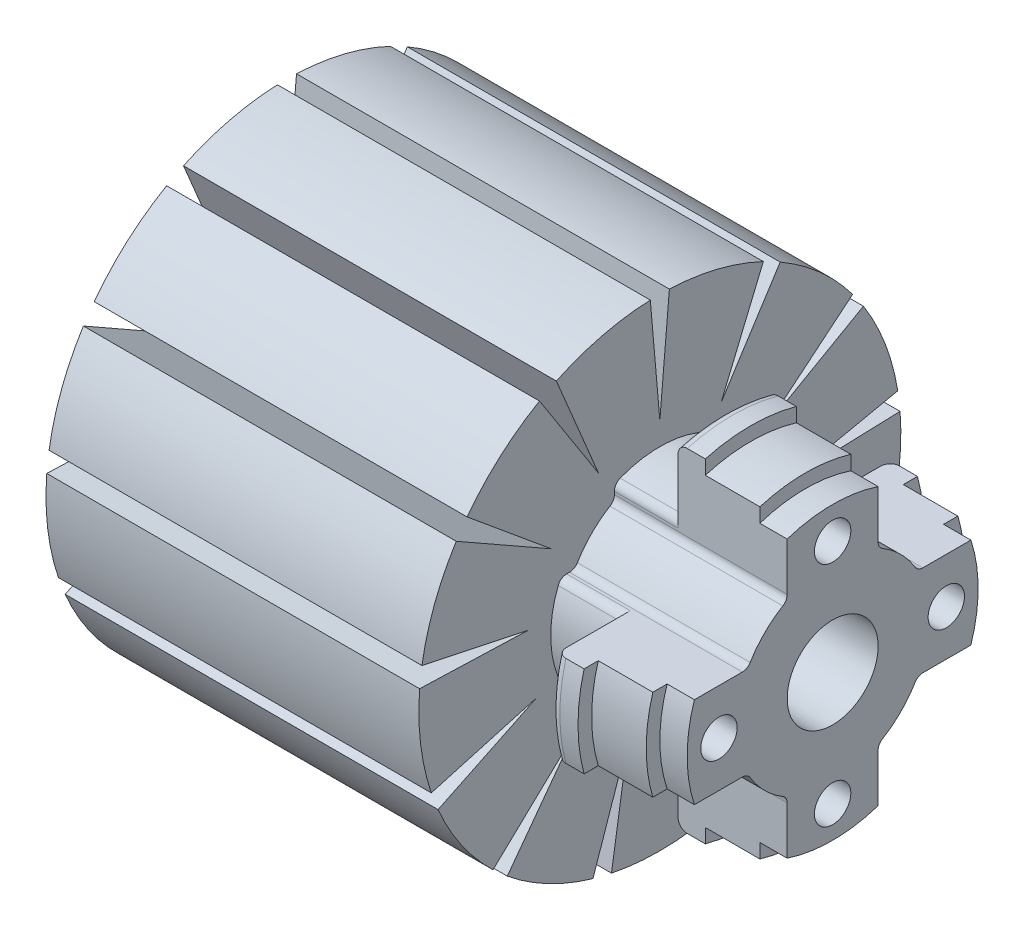
from build123d import *

# Parameters (mm, degrees)
SKETCH1_R      = 26.5
SKETCH1_R_2    = 5
EXTRUDE1_DEPTH = 60
SKETCH3_R      = 2
EXTRUDE2_DEPTH = 10
EXTRUDE3_START = -41
EXTRUDE3_DEPTH = 41
EXTRUDE4_DEPTH = 19
FILLET1_R      = 1


with BuildPart() as part:
    # Sketch1 → Extrude1 (new body)
    with BuildSketch(Plane(origin=(0, 0, 0), x_dir=(0, 0, -1), z_dir=(1, 0, 0))):
        Circle(SKETCH1_R)
        Circle(SKETCH1_R_2, mode=Mode.SUBTRACT)
    extrude(amount=EXTRUDE1_DEPTH)

    # Sketch2 → Cut-Revolve1 (revolve, cut)
    with BuildSketch(Plane.XY):
        Polygon((60, 16), (60, 26.5), (41, 26.5), (41, 12), (48, 12), (48, 19), (51, 19), (51, 17.5), (57, 17.5), (57, 16), align=None)
    revolve(axis=Axis((0, 0, 0), (1, 0, 0)), mode=Mode.SUBTRACT)

    # Sketch3 → Extrude2 (cut)
    with BuildSketch(Plane(origin=(60, 0, 0), x_dir=(0, 0, -1), z_dir=(1, 0, 0))):
        with Locations((0, 12.5)):
            Circle(SKETCH3_R)
        with Locations((12.5, 0)):
            Circle(SKETCH3_R)
        with Locations((0, -12.5)):
            Circle(SKETCH3_R)
        with Locations((-12.5, 0)):
            Circle(SKETCH3_R)
    extrude(amount=-EXTRUDE2_DEPTH, mode=Mode.SUBTRACT)

    # Sketch4 → Extrude3 (cut)
    with BuildSketch(Plane.ZY.offset(EXTRUDE3_START)):
        with BuildLine():
            Line((0, 14.5), (1.048050077, 26.479267192))
            ThreePointArc((1.048050077, 26.479267192), (0, 26.5), (-1.048050077, 26.479267192))
            Line((-1.048050077, 26.479267192), (0, 14.5))
        make_face()
        with BuildLine():
            Line((11.377526787, 23.933279846), (6.738485995, 12.839112372))
            Line((6.738485995, 12.839112372), (13.233531299, 22.959173534))
            ThreePointArc((13.233531299, 22.959173534), (12.315164059, 23.46458468), (11.377526787, 23.933279846))
        make_face()
        with BuildLine():
            Line((-6.738485995, 12.839112372), (-11.377526787, 23.933279846))
            ThreePointArc((-11.377526787, 23.933279846), (-12.315164059, 23.46458468), (-13.233531299, 22.959173534))
            Line((-13.233531299, 22.959173534), (-6.738485995, 12.839112372))
        make_face()
        with BuildLine():
            Line((21.196649379, 15.904466515), (11.933266055, 8.236938828))
            Line((11.933266055, 8.236938828), (22.387369981, 14.179409907))
            ThreePointArc((22.387369981, 14.179409907), (21.809072446, 15.053715788), (21.196649379, 15.904466515))
        make_face()
        with BuildLine():
            Line((-11.933266055, 8.236938828), (-21.196649379, 15.904466515))
            ThreePointArc((-21.196649379, 15.904466515), (-21.809072446, 15.053715788), (-22.387369981, 14.179409907))
            Line((-22.387369981, 14.179409907), (-11.933266055, 8.236938828))
        make_face()
        with BuildLine():
            Line((26.159875044, 4.232131575), (14.394278674, 1.747781864))
            Line((14.394278674, 1.747781864), (26.412531998, 2.151314351))
            ThreePointArc((26.412531998, 2.151314351), (26.306785164, 3.194222027), (26.159875044, 4.232131575))
        make_face()
        with BuildLine():
            Line((-14.394278674, 1.747781864), (-26.159875044, 4.232131575))
            ThreePointArc((-26.159875044, 4.232131575), (-26.306785164, 3.194222027), (-26.412531998, 2.151314351))
            Line((-26.412531998, 2.151314351), (-14.394278674, 1.747781864))
        make_face()
        with BuildLine():
            Line((25.130188598, -8.409733707), (13.557735519, -5.141770862))
            Line((13.557735519, -5.141770862), (24.38690124, -10.369621396))
            ThreePointArc((24.38690124, -10.369621396), (24.777930431, -9.397029507), (25.130188598, -8.409733707))
        make_face()
        with BuildLine():
            Line((-13.557735519, -5.141770862), (-25.130188598, -8.409733707))
            ThreePointArc((-25.130188598, -8.409733707), (-24.777930431, -9.397029507), (-24.38690124, -10.369621396))
            Line((-24.38690124, -10.369621396), (-13.557735519, -5.141770862))
        make_face()
        with BuildLine():
            Line((18.343478796, -19.125030344), (9.615278544, -10.853405848))
            Line((9.615278544, -10.853405848), (16.774525302, -20.51500185))
            ThreePointArc((16.774525302, -20.51500185), (17.572750443, -19.835534827), (18.343478796, -19.125030344))
        make_face()
        with BuildLine():
            Line((-9.615278544, -10.853405848), (-18.343478796, -19.125030344))
            ThreePointArc((-18.343478796, -19.125030344), (-17.572750443, -19.835534827), (-16.774525302, -20.51500185))
            Line((-16.774525302, -20.51500185), (-9.615278544, -10.853405848))
        make_face()
        with BuildLine():
            Line((7.354499064, -25.459013011), (3.470077132, -14.078656353))
            Line((3.470077132, -14.078656353), (5.319307772, -25.960642612))
            ThreePointArc((5.319307772, -25.960642612), (6.341865104, -25.729958162), (7.354499064, -25.459013011))
        make_face()
        with BuildLine():
            Line((-3.470077132, -14.078656353), (-7.354499064, -25.459013011))
            ThreePointArc((-7.354499064, -25.459013011), (-6.341865104, -25.729958162), (-5.319307772, -25.960642612))
            Line((-5.319307772, -25.960642612), (-3.470077132, -14.078656353))
        make_face()
    extrude(amount=EXTRUDE3_DEPTH, mode=Mode.SUBTRACT)

    # Sketch5 → Extrude4 (cut)
    with BuildSketch(Plane(origin=(60, 0, 0), x_dir=(0, 0, -1), z_dir=(1, 0, 0))):
        with BuildLine():
            Line((-5, 9.346657156), (-5, 15.198684154))
            ThreePointArc((-5, 15.198684154), (-11.313708499, 11.313708499), (-15.198684154, 5))
            Line((-15.198684154, 5), (-9.346657156, 5))
            ThreePointArc((-9.346657156, 5), (-7.495331881, 7.495331881), (-5, 9.346657156))
        make_face()
        with BuildLine():
            Line((-5, 15.198684154), (-5, 18.33030278))
            ThreePointArc((-5, 18.33030278), (-13.435028843, 13.435028843), (-18.33030278, 5))
            Line((-18.33030278, 5), (-15.198684154, 5))
            ThreePointArc((-15.198684154, 5), (-11.313708499, 11.313708499), (-5, 15.198684154))
        make_face()
        with BuildLine():
            ThreePointArc((15.198684154, 5), (11.313708499, 11.313708499), (5, 15.198684154))
            Line((5, 15.198684154), (5, 9.346657156))
            ThreePointArc((5, 9.346657156), (7.495331881, 7.495331881), (9.346657156, 5))
            Line((9.346657156, 5), (15.198684154, 5))
        make_face()
        with BuildLine():
            ThreePointArc((18.33030278, 5), (13.435028843, 13.435028843), (5, 18.33030278))
            Line((5, 18.33030278), (5, 15.198684154))
            ThreePointArc((5, 15.198684154), (11.313708499, 11.313708499), (15.198684154, 5))
            Line((15.198684154, 5), (18.33030278, 5))
        make_face()
        with BuildLine():
            ThreePointArc((5, -15.198684154), (11.313708499, -11.313708499), (15.198684154, -5))
            Line((15.198684154, -5), (9.346657156, -5))
            ThreePointArc((9.346657156, -5), (7.495331881, -7.495331881), (5, -9.346657156))
            Line((5, -9.346657156), (5, -15.198684154))
        make_face()
        with BuildLine():
            ThreePointArc((5, -18.33030278), (13.435028843, -13.435028843), (18.33030278, -5))
            Line((18.33030278, -5), (15.198684154, -5))
            ThreePointArc((15.198684154, -5), (11.313708499, -11.313708499), (5, -15.198684154))
            Line((5, -15.198684154), (5, -18.33030278))
        make_face()
        with BuildLine():
            Line((-9.346657156, -5), (-15.198684154, -5))
            ThreePointArc((-15.198684154, -5), (-11.313708499, -11.313708499), (-5, -15.198684154))
            Line((-5, -15.198684154), (-5, -9.346657156))
            ThreePointArc((-5, -9.346657156), (-7.495331881, -7.495331881), (-9.346657156, -5))
        make_face()
        with BuildLine():
            Line((-15.198684154, -5), (-18.33030278, -5))
            ThreePointArc((-18.33030278, -5), (-13.435028843, -13.435028843), (-5, -18.33030278))
            Line((-5, -18.33030278), (-5, -15.198684154))
            ThreePointArc((-5, -15.198684154), (-11.313708499, -11.313708499), (-15.198684154, -5))
        make_face()
    extrude(amount=-EXTRUDE4_DEPTH, mode=Mode.SUBTRACT)

    # Fillet1
    fillet1_edges = [part.edges().sort_by_distance(p)[0] for p in [
        (48, 19, 0),
        (44.5, 10.908712115, 5),
        (50.5, 5, 9.346657156),
        (44.5, 5, 10.908712115),
        (50.5, 9.346657156, 5),
        (48, 0, -19),
        (44.5, 5, -10.908712115),
        (50.5, 9.346657156, -5),
        (44.5, 10.908712115, -5),
        (50.5, 5, -9.346657156),
        (48, -19, 0),
        (44.5, -10.908712115, -5),
        (50.5, -5, -9.346657156),
        (44.5, -5, -10.908712115),
        (50.5, -9.346657156, -5),
        (48, 0, 19),
        (44.5, -5, 10.908712115),
        (50.5, -9.346657156, 5),
        (44.5, -10.908712115, 5),
        (50.5, -5, 9.346657156),
    ]]
    fillet(fillet1_edges, radius=FILLET1_R)


solid = part.part
